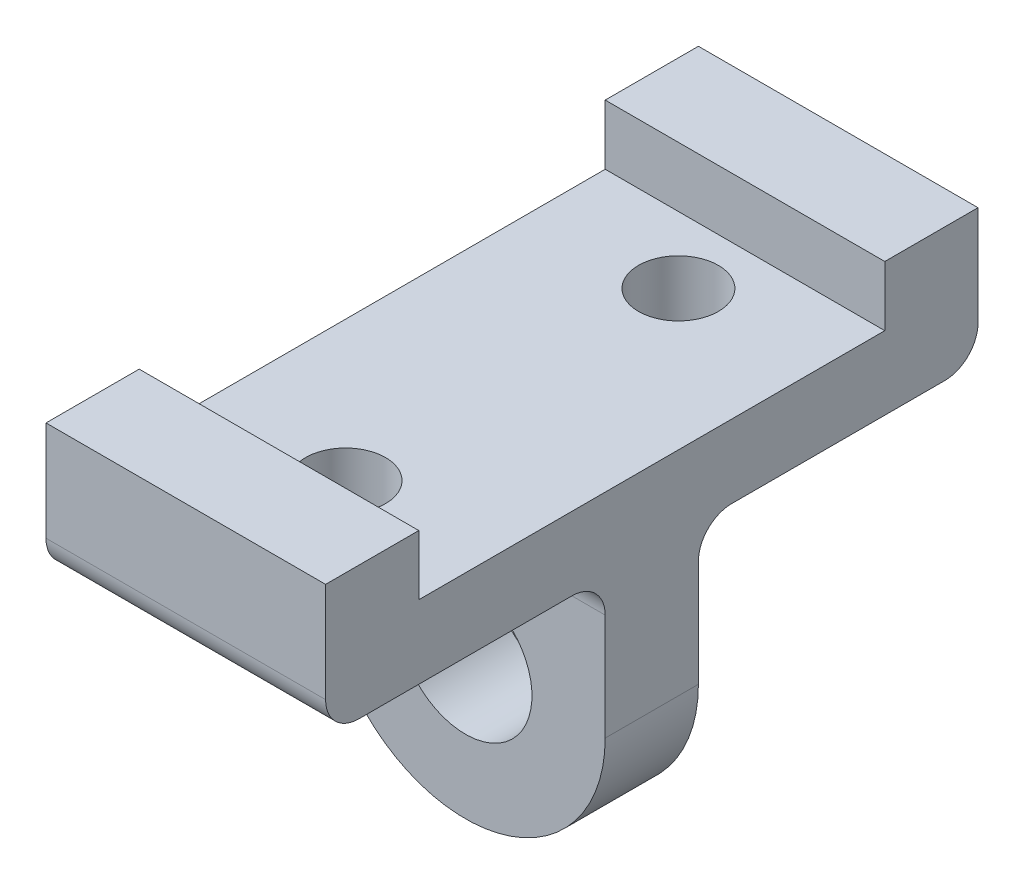
from build123d import *

# Parameters (mm, degrees)
SKETCH1_W           = 42
SKETCH1_H           = 98
BOSS_EXTRUDE1_DEPTH = 20
SKETCH2_W           = 42
SKETCH2_H           = 70
CUT_EXTRUDE1_DEPTH  = 9
SKETCH4_W           = 42
SKETCH4_H           = 14
BOSS_EXTRUDE2_DEPTH = 21
SKETCH5_W           = 21
SKETCH5_H           = 14
REVOLVE1_ANGLE      = 180
SKETCH3_R           = 6
CUT_EXTRUDE2_DEPTH  = 21
SKETCH6_R           = 10
CUT_EXTRUDE3_DEPTH  = 21
FILLET1_R           = 5


with BuildPart() as part:
    # Sketch1 → Boss-Extrude1 (new body)
    with BuildSketch(Plane(origin=(0, 0, 0), x_dir=(1, 0, 0), z_dir=(0, 1, 0))):
        Rectangle(SKETCH1_W, SKETCH1_H)
    extrude(amount=BOSS_EXTRUDE1_DEPTH)

    # Sketch2 → Cut-Extrude1 (cut)
    with BuildSketch(Plane(origin=(0, 20, 0), x_dir=(1, 0, 0), z_dir=(0, 1, 0))):
        Rectangle(SKETCH2_W, SKETCH2_H)
    extrude(amount=-CUT_EXTRUDE1_DEPTH, mode=Mode.SUBTRACT)

    # Sketch4 → Boss-Extrude2 (add)
    with BuildSketch(Plane.XZ):
        Rectangle(SKETCH4_W, SKETCH4_H)
    extrude(amount=BOSS_EXTRUDE2_DEPTH)

    # Sketch5 → Revolve1 (revolve)
    with BuildSketch(Plane.XZ.offset(21)):
        with Locations((10.5, 0)):
            Rectangle(SKETCH5_W, SKETCH5_H)
    revolve(axis=Axis((0, -21, 7), (0, 0, -1)), revolution_arc=REVOLVE1_ANGLE)

    # Sketch3 → Cut-Extrude2 (cut)
    with BuildSketch(Plane.XZ):
        with Locations((0, -25)):
            Circle(SKETCH3_R)
        with Locations((0, 25)):
            Circle(SKETCH3_R)
    extrude(amount=-CUT_EXTRUDE2_DEPTH, mode=Mode.SUBTRACT)

    # Sketch6 → Cut-Extrude3 (cut)
    with BuildSketch(Plane(origin=(0, 0, -7), x_dir=(-1, 0, 0), z_dir=(0, 0, -1))):
        with Locations((0, -21)):
            Circle(SKETCH6_R)
    extrude(amount=-CUT_EXTRUDE3_DEPTH, mode=Mode.SUBTRACT)

    # Fillet1
    fillet1_edges = [part.edges().sort_by_distance(p)[0] for p in [
        (0, 0, -7),
        (0, 0, 7),
        (0, 0, 49),
        (0, 0, -49),
    ]]
    fillet(fillet1_edges, radius=FILLET1_R)


solid = part.part
